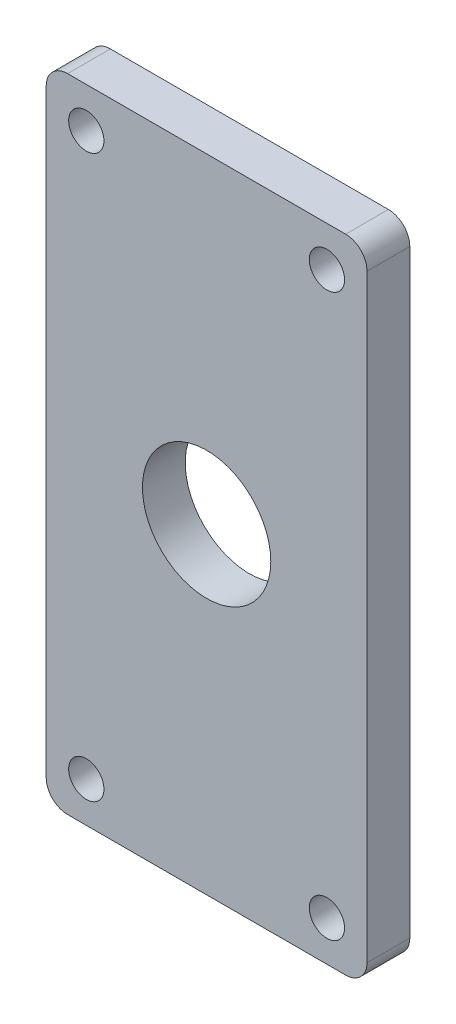
from build123d import *

# Parameters (mm, degrees)
SKETCH_6_R         = 6
EXTRUDE_4_DEPTH    = 4
FILLET_2_R         = 2
FILLET_6_R         = 2
FILLET_12_R        = 2
FILLET_16_R        = 2
HOLE_WIZARD_M4_1_D = 3.3


with BuildPart() as part:
    # 草图6 → 凸台-拉伸4 (new body)
    with BuildSketch(Plane.XY):
        Polygon((-15, -22.5), (-15, -30), (-7.5, -30), (7.5, -30), (15, -30), (15, -22.5), (15, 22.5), (15, 30), (7.5, 30), (-7.5, 30), (-15, 30), (-15, 22.5), align=None)
        Circle(SKETCH_6_R, mode=Mode.SUBTRACT)
    extrude(amount=EXTRUDE_4_DEPTH)

    # 圆角2
    fillet_2_edges = [part.edges().sort_by_distance(p)[0] for p in [
        (15, 30, 2),
    ]]
    fillet(fillet_2_edges, radius=FILLET_2_R)

    # 圆角6
    fillet_6_edges = [part.edges().sort_by_distance(p)[0] for p in [
        (15, -30, 2),
    ]]
    fillet(fillet_6_edges, radius=FILLET_6_R)

    # 圆角12
    fillet_12_edges = [part.edges().sort_by_distance(p)[0] for p in [
        (-15, 30, 2),
    ]]
    fillet(fillet_12_edges, radius=FILLET_12_R)

    # 圆角16
    fillet_16_edges = [part.edges().sort_by_distance(p)[0] for p in [
        (-15, -30, 2),
    ]]
    fillet(fillet_16_edges, radius=FILLET_16_R)

    # M4 螺纹孔1 (through all)
    with Locations(Plane.XY.offset(4)):
        with Locations((-11.25, 26.25), (11.25, 26.25), (11.25, -26.25), (-11.25, -26.25)):
            Hole(HOLE_WIZARD_M4_1_D / 2)


solid = part.part
